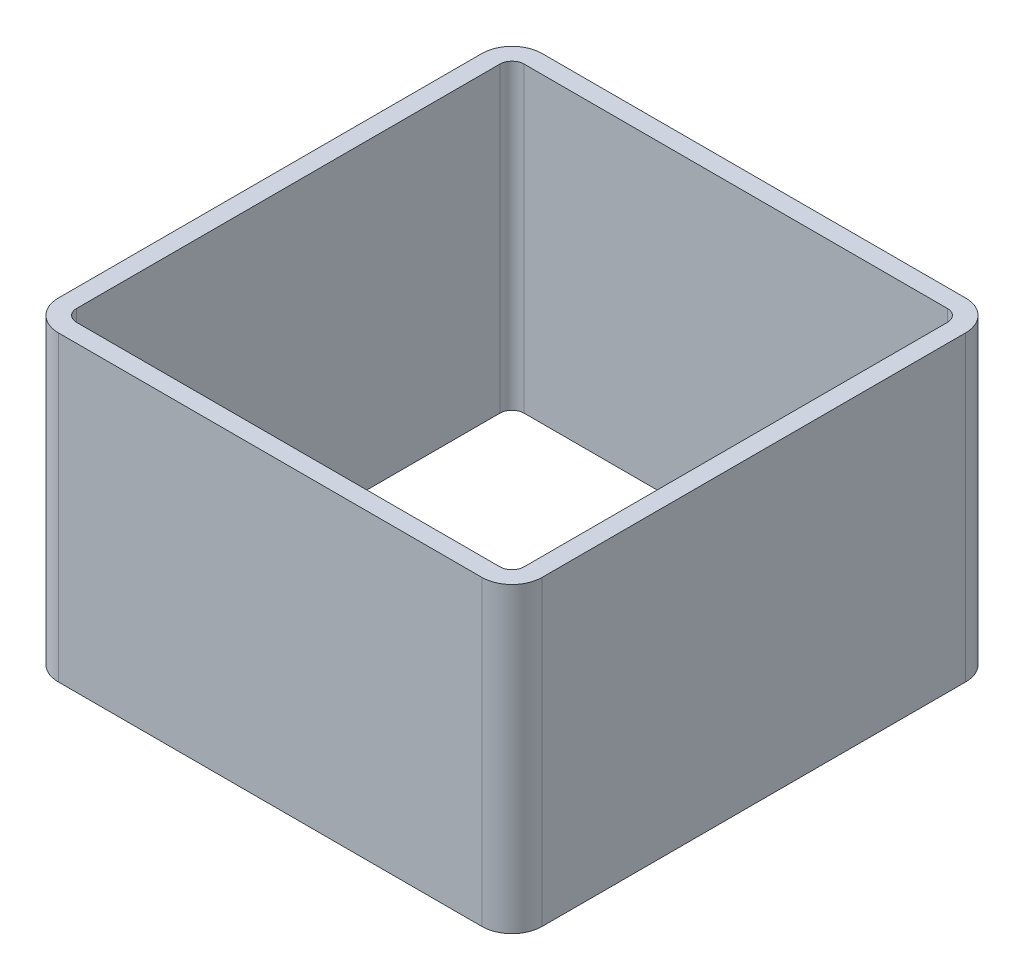
from build123d import *

# Parameters (mm, degrees)
EXTRUDE_1_DEPTH = 50


with BuildPart() as part:
    # Эскиз1 → Вытянуть-Тонкостенный1 (new body)
    with BuildSketch(Plane(origin=(0, 0, 0), x_dir=(1, 0, 0), z_dir=(0, 1, 0))):
        with BuildLine():
            Line((-35, 40), (35, 40))
            ThreePointArc((35, 40), (38.535533906, 38.535533906), (40, 35))
            Line((40, 35), (40, -35))
            ThreePointArc((40, -35), (38.535533906, -38.535533906), (35, -40))
            Line((35, -40), (-35, -40))
            ThreePointArc((-35, -40), (-38.535533906, -38.535533906), (-40, -35))
            Line((-40, -35), (-40, 35))
            ThreePointArc((-40, 35), (-38.535533906, 38.535533906), (-35, 40))
        make_face()
        with BuildLine():
            Line((-35, 37), (35, 37))
            ThreePointArc((35, 37), (36.414213562, 36.414213562), (37, 35))
            Line((37, 35), (37, -35))
            ThreePointArc((37, -35), (36.414213562, -36.414213562), (35, -37))
            Line((35, -37), (-35, -37))
            ThreePointArc((-35, -37), (-36.414213562, -36.414213562), (-37, -35))
            Line((-37, -35), (-37, 35))
            ThreePointArc((-37, 35), (-36.414213562, 36.414213562), (-35, 37))
        make_face(mode=Mode.SUBTRACT)
    extrude(amount=EXTRUDE_1_DEPTH)


solid = part.part
